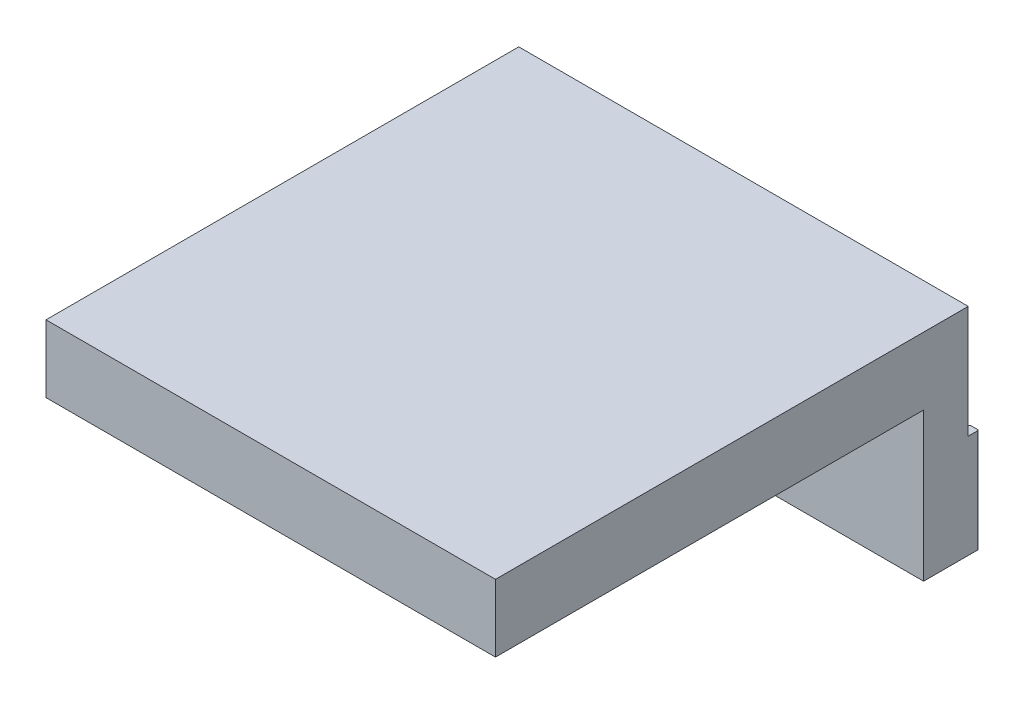
from build123d import *

# Parameters (mm, degrees)
RESSALTO_EXTRUS_O2_DEPTH = 9.2
ESBO_O5_R                = 2.15
CORTE_EXTRUS_O2_DEPTH    = 9.2
CHANFRO2_SIZE            = 0.3
SKETCH1_W                = 40
SKETCH1_H                = 3.972261678
BOSS_EXTRUDE1_DEPTH      = 10
SKETCH2_W                = 40
SKETCH2_H                = 6
BOSS_EXTRUDE2_DEPTH      = 38.1


with BuildPart() as part:
    # Esboço4 → Ressalto-extrusão2 (new body)
    with BuildSketch(Plane(origin=(0, 0, 0), x_dir=(1, 0, 0), z_dir=(0, 1, 0))):
        with BuildLine():
            Line((-19.2, 2.35), (-19.2, 1.65))
            ThreePointArc((-19.2, 1.65), (-19.170710678, 1.579289322), (-19.1, 1.55))
            Line((-19.1, 1.55), (-18.1, 1.55))
            ThreePointArc((-18.1, 1.55), (-18.029289322, 1.579289322), (-18, 1.65))
            Line((-18, 1.65), (-18, 2.35))
            ThreePointArc((-18, 2.35), (-17.970710678, 2.420710678), (-17.9, 2.45))
            Line((-17.9, 2.45), (-17.3, 2.45))
            ThreePointArc((-17.3, 2.45), (-17.229289322, 2.420710678), (-17.2, 2.35))
            Line((-17.2, 2.35), (-17.2, 1.65))
            ThreePointArc((-17.2, 1.65), (-17.170710678, 1.579289322), (-17.1, 1.55))
            Line((-17.1, 1.55), (-16.1, 1.55))
            ThreePointArc((-16.1, 1.55), (-16.029289322, 1.579289322), (-16, 1.65))
            Line((-16, 1.65), (-16, 2.35))
            ThreePointArc((-16, 2.35), (-15.970710678, 2.420710678), (-15.9, 2.45))
            Line((-15.9, 2.45), (-15.3, 2.45))
            ThreePointArc((-15.3, 2.45), (-15.229289322, 2.420710678), (-15.2, 2.35))
            Line((-15.2, 2.35), (-15.2, 1.65))
            ThreePointArc((-15.2, 1.65), (-15.170710678, 1.579289322), (-15.1, 1.55))
            Line((-15.1, 1.55), (-14.1, 1.55))
            ThreePointArc((-14.1, 1.55), (-14.029289322, 1.579289322), (-14, 1.65))
            Line((-14, 1.65), (-14, 2.35))
            ThreePointArc((-14, 2.35), (-13.970710678, 2.420710678), (-13.9, 2.45))
            Line((-13.9, 2.45), (-13.3, 2.45))
            ThreePointArc((-13.3, 2.45), (-13.229289322, 2.420710678), (-13.2, 2.35))
            Line((-13.2, 2.35), (-13.2, 1.65))
            ThreePointArc((-13.2, 1.65), (-13.170710678, 1.579289322), (-13.1, 1.55))
            Line((-13.1, 1.55), (-12.1, 1.55))
            ThreePointArc((-12.1, 1.55), (-12.029289322, 1.579289322), (-12, 1.65))
            Line((-12, 1.65), (-12, 2.35))
            ThreePointArc((-12, 2.35), (-11.970710678, 2.420710678), (-11.9, 2.45))
            Line((-11.9, 2.45), (-11.3, 2.45))
            ThreePointArc((-11.3, 2.45), (-11.229289322, 2.420710678), (-11.2, 2.35))
            Line((-11.2, 2.35), (-11.2, 1.65))
            ThreePointArc((-11.2, 1.65), (-11.170710678, 1.579289322), (-11.1, 1.55))
            Line((-11.1, 1.55), (-10.1, 1.55))
            ThreePointArc((-10.1, 1.55), (-10.029289322, 1.579289322), (-10, 1.65))
            Line((-10, 1.65), (-10, 2.35))
            ThreePointArc((-10, 2.35), (-9.970710678, 2.420710678), (-9.9, 2.45))
            Line((-9.9, 2.45), (-9.3, 2.45))
            ThreePointArc((-9.3, 2.45), (-9.229289322, 2.420710678), (-9.2, 2.35))
            Line((-9.2, 2.35), (-9.2, 1.65))
            ThreePointArc((-9.2, 1.65), (-9.170710678, 1.579289322), (-9.1, 1.55))
            Line((-9.1, 1.55), (-8.1, 1.55))
            ThreePointArc((-8.1, 1.55), (-8.029289322, 1.579289322), (-8, 1.65))
            Line((-8, 1.65), (-8, 2.35))
            ThreePointArc((-8, 2.35), (-7.970710678, 2.420710678), (-7.9, 2.45))
            Line((-7.9, 2.45), (-7.3, 2.45))
            ThreePointArc((-7.3, 2.45), (-7.229289322, 2.420710678), (-7.2, 2.35))
            Line((-7.2, 2.35), (-7.2, 1.65))
            ThreePointArc((-7.2, 1.65), (-7.170710678, 1.579289322), (-7.1, 1.55))
            Line((-7.1, 1.55), (7.1, 1.55))
            ThreePointArc((7.1, 1.55), (7.170710678, 1.579289322), (7.2, 1.65))
            Line((7.2, 1.65), (7.2, 2.35))
            ThreePointArc((7.2, 2.35), (7.229289322, 2.420710678), (7.3, 2.45))
            Line((7.3, 2.45), (7.9, 2.45))
            ThreePointArc((7.9, 2.45), (7.970710678, 2.420710678), (8, 2.35))
            Line((8, 2.35), (8, 1.65))
            ThreePointArc((8, 1.65), (8.029289322, 1.579289322), (8.1, 1.55))
            Line((8.1, 1.55), (9.1, 1.55))
            ThreePointArc((9.1, 1.55), (9.170710678, 1.579289322), (9.2, 1.65))
            Line((9.2, 1.65), (9.2, 2.35))
            ThreePointArc((9.2, 2.35), (9.229289322, 2.420710678), (9.3, 2.45))
            Line((9.3, 2.45), (9.9, 2.45))
            ThreePointArc((9.9, 2.45), (9.970710678, 2.420710678), (10, 2.35))
            Line((10, 2.35), (10, 1.65))
            ThreePointArc((10, 1.65), (10.029289322, 1.579289322), (10.1, 1.55))
            Line((10.1, 1.55), (11.1, 1.55))
            ThreePointArc((11.1, 1.55), (11.170710678, 1.579289322), (11.2, 1.65))
            Line((11.2, 1.65), (11.2, 2.35))
            ThreePointArc((11.2, 2.35), (11.229289322, 2.420710678), (11.3, 2.45))
            Line((11.3, 2.45), (11.9, 2.45))
            ThreePointArc((11.9, 2.45), (11.970710678, 2.420710678), (12, 2.35))
            Line((12, 2.35), (12, 1.65))
            ThreePointArc((12, 1.65), (12.029289322, 1.579289322), (12.1, 1.55))
            Line((12.1, 1.55), (13.1, 1.55))
            ThreePointArc((13.1, 1.55), (13.170710678, 1.579289322), (13.2, 1.65))
            Line((13.2, 1.65), (13.2, 2.35))
            ThreePointArc((13.2, 2.35), (13.229289322, 2.420710678), (13.3, 2.45))
            Line((13.3, 2.45), (13.9, 2.45))
            ThreePointArc((13.9, 2.45), (13.970710678, 2.420710678), (14, 2.35))
            Line((14, 2.35), (14, 1.65))
            ThreePointArc((14, 1.65), (14.029289322, 1.579289322), (14.1, 1.55))
            Line((14.1, 1.55), (15.1, 1.55))
            ThreePointArc((15.1, 1.55), (15.170710678, 1.579289322), (15.2, 1.65))
            Line((15.2, 1.65), (15.2, 2.35))
            ThreePointArc((15.2, 2.35), (15.229289322, 2.420710678), (15.3, 2.45))
            Line((15.3, 2.45), (15.9, 2.45))
            ThreePointArc((15.9, 2.45), (15.970710678, 2.420710678), (16, 2.35))
            Line((16, 2.35), (16, 1.65))
            ThreePointArc((16, 1.65), (16.029289322, 1.579289322), (16.1, 1.55))
            Line((16.1, 1.55), (17.1, 1.55))
            ThreePointArc((17.1, 1.55), (17.170710678, 1.579289322), (17.2, 1.65))
            Line((17.2, 1.65), (17.2, 2.35))
            ThreePointArc((17.2, 2.35), (17.229289322, 2.420710678), (17.3, 2.45))
            Line((17.3, 2.45), (17.9, 2.45))
            ThreePointArc((17.9, 2.45), (17.970710678, 2.420710678), (18, 2.35))
            Line((18, 2.35), (18, 1.65))
            ThreePointArc((18, 1.65), (18.029289322, 1.579289322), (18.1, 1.55))
            Line((18.1, 1.55), (19.1, 1.55))
            ThreePointArc((19.1, 1.55), (19.170710678, 1.579289322), (19.2, 1.65))
            Line((19.2, 1.65), (19.2, 2.35))
            ThreePointArc((19.2, 2.35), (19.229289322, 2.420710678), (19.3, 2.45))
            Line((19.3, 2.45), (19.9, 2.45))
            ThreePointArc((19.9, 2.45), (19.970710678, 2.420710678), (20, 2.35))
            Line((20, 2.35), (20, -2.45))
            Line((20, -2.45), (-20, -2.45))
            Line((-20, -2.45), (-20, 2.35))
            ThreePointArc((-20, 2.35), (-19.970710678, 2.420710678), (-19.9, 2.45))
            Line((-19.9, 2.45), (-19.3, 2.45))
            ThreePointArc((-19.3, 2.45), (-19.229289322, 2.420710678), (-19.2, 2.35))
        make_face()
    extrude(amount=RESSALTO_EXTRUS_O2_DEPTH)

    # Esboço5 → Corte-extrusão2 (cut)
    with BuildSketch(Plane(origin=(0, 0, -1.55), x_dir=(-1, 0, 0), z_dir=(0, 0, -1))):
        with Locations((0, 4.6)):
            Circle(ESBO_O5_R)
    extrude(amount=-CORTE_EXTRUS_O2_DEPTH, mode=Mode.SUBTRACT)

    # Chanfro2
    chanfro2_edges = [part.edges().sort_by_distance(p)[0] for p in [
        (2.15, 4.6, -1.55),
    ]]
    chamfer(chanfro2_edges, length=CHANFRO2_SIZE)

    # Sketch1 → Boss-Extrude1 (add)
    with BuildSketch(Plane(origin=(0, 9.2, 0), x_dir=(1, 0, 0), z_dir=(0, 1, 0))):
        with Locations((0, -0.463869161)):
            Rectangle(SKETCH1_W, SKETCH1_H)
    extrude(amount=BOSS_EXTRUDE1_DEPTH)

    # Sketch2 → Boss-Extrude2 (add)
    with BuildSketch(Plane.XY.offset(2.45)):
        with Locations((0, 16.2)):
            Rectangle(SKETCH2_W, SKETCH2_H)
    extrude(amount=BOSS_EXTRUDE2_DEPTH)


solid = part.part
